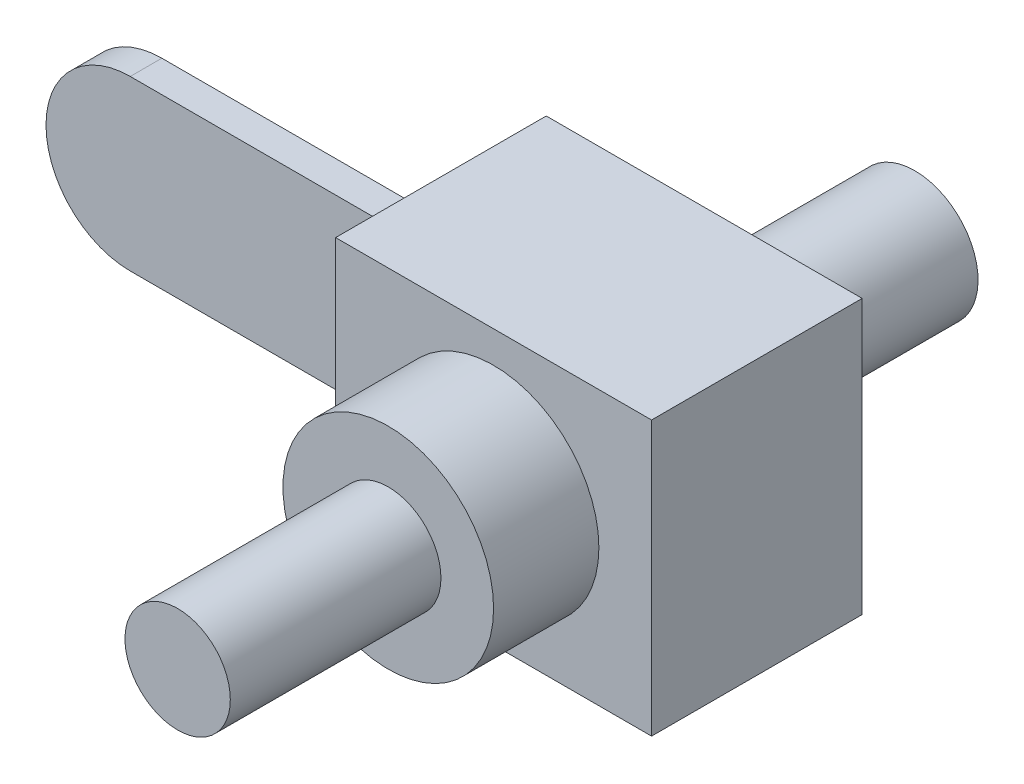
from build123d import *

# Parameters (mm, degrees)
BOSS_EXTRUDE1_DEPTH = 7.5
SKETCH3_W           = 100
SKETCH3_H           = 130
BOSS_EXTRUDE2_DEPTH = 150
SKETCH4_R           = 30
BOSS_EXTRUDE3_DEPTH = 100
SKETCH5_R           = 50
BOSS_EXTRUDE4_DEPTH = 50
SKETCH6_R           = 25
BOSS_EXTRUDE5_DEPTH = 100


with BuildPart() as part:
    # Sketch1 → Boss-Extrude1 (new body, symmetric)
    with BuildSketch(Plane.XY):
        with BuildLine():
            Line((0, 40), (140, 40))
            Line((140, 40), (140, -40))
            Line((140, -40), (0, -40))
            ThreePointArc((0, -40), (-40, 0), (0, 40))
        make_face()
    extrude(amount=BOSS_EXTRUDE1_DEPTH, both=True)

    # Sketch3 → Boss-Extrude2 (add)
    with BuildSketch(Plane(origin=(140, 0, 0), x_dir=(0, 0, -1), z_dir=(1, 0, 0))):
        Rectangle(SKETCH3_W, SKETCH3_H)
    extrude(amount=BOSS_EXTRUDE2_DEPTH)

    # Sketch4 → Boss-Extrude3 (add)
    with BuildSketch(Plane(origin=(0, 0, -50), x_dir=(-1, 0, 0), z_dir=(0, 0, -1))):
        with Locations((-215, 0)):
            Circle(SKETCH4_R)
    extrude(amount=BOSS_EXTRUDE3_DEPTH)

    # Sketch5 → Boss-Extrude4 (add)
    with BuildSketch(Plane.XY.offset(50)):
        with Locations((215, 0)):
            Circle(SKETCH5_R)
    extrude(amount=BOSS_EXTRUDE4_DEPTH)

    # Sketch6 → Boss-Extrude5 (add)
    with BuildSketch(Plane.XY.offset(100)):
        with Locations((215, 0)):
            Circle(SKETCH6_R)
    extrude(amount=BOSS_EXTRUDE5_DEPTH)


solid = part.part
